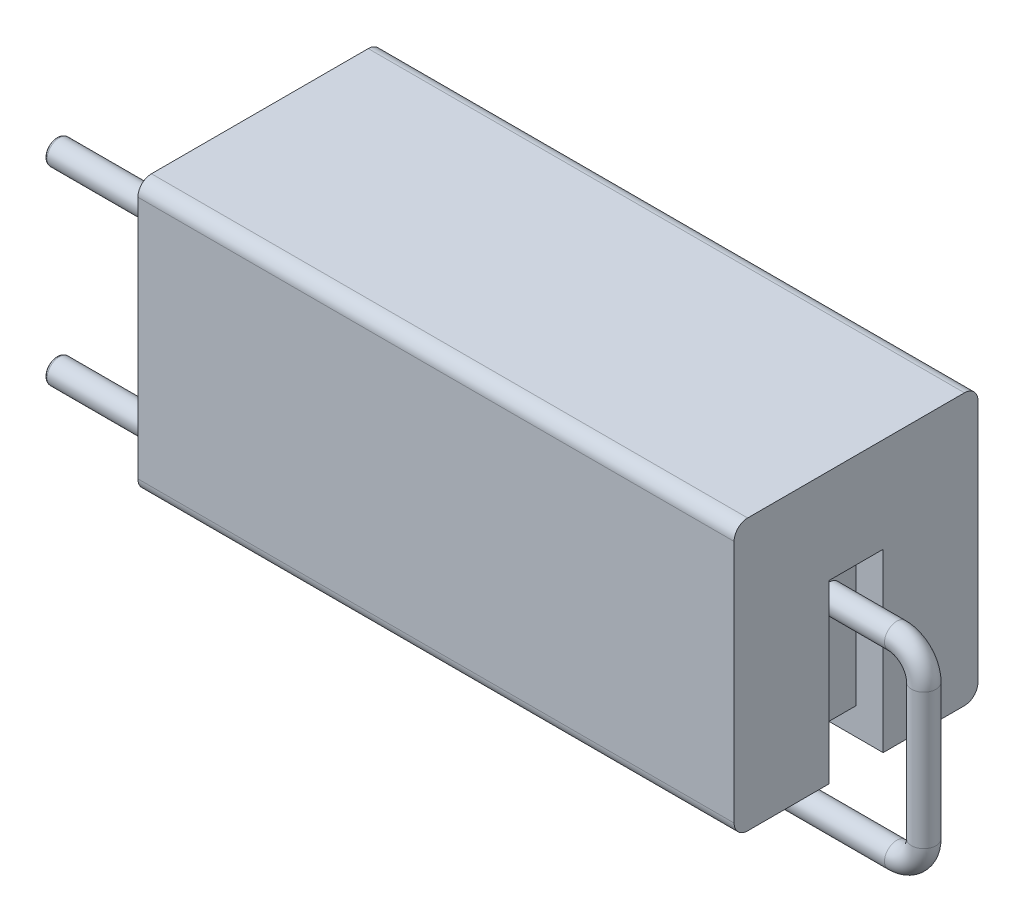
from build123d import *

# Parameters (mm, degrees)
SKETCH1_W           = 22
SKETCH1_H           = 10
BOSS_EXTRUDE1_DEPTH = 9
FILLET2_R           = 0.5
CUT_EXTRUDE4_DEPTH  = 1
SKETCH8_W           = 2
SKETCH8_H           = 6.5
CUT_EXTRUDE5_DEPTH  = 1
CUT_EXTRUDE6_DEPTH  = 1
SKETCH14_R          = 0.45
SKETCH15_R          = 0.45
FILLET4_R           = 0.1


with BuildPart() as part:
    # Sketch1 → Boss-Extrude1 (new body)
    with BuildSketch(Plane.XY):
        with Locations((11, -5)):
            Rectangle(SKETCH1_W, SKETCH1_H)
    extrude(amount=BOSS_EXTRUDE1_DEPTH)

    # Fillet2
    fillet2_edges = [part.edges().sort_by_distance(p)[0] for p in [
        (11, 0, 9),
        (11, 0, 0),
        (11, -10, 0),
        (11, -10, 9),
    ]]
    fillet(fillet2_edges, radius=FILLET2_R)

    # 3DSketch1 → Cut-Extrude4 (cut)
    with BuildSketch(Plane(origin=(22, -10, 5.5), x_dir=(0, 0.9557790087219501, -0.29408584883752314), z_dir=(1, 0, 0))):
        Polygon((0, 0), (6.212563557, 1.911558017), (6.800735254, 0), (0.588171698, -1.911558017), align=None)
    extrude(amount=-CUT_EXTRUDE4_DEPTH, mode=Mode.SUBTRACT)

    # Sketch8 → Cut-Extrude5 (cut)
    with BuildSketch(Plane.ZY):
        with Locations((4.5, -6.75)):
            Rectangle(SKETCH8_W, SKETCH8_H)
    extrude(amount=-CUT_EXTRUDE5_DEPTH, mode=Mode.SUBTRACT)

    # Sketch6 → Cut-Extrude6 (cut)
    with BuildSketch(Plane.XZ.offset(10)):
        Polygon((1, 5.5), (1, 3.5), (3, 3.5), (3, 1), (19, 1), (19, 3.5), (21, 3.5), (21, 5.5), (19, 5.5), (19, 8), (3, 8), (3, 5.5), align=None)
    extrude(amount=-CUT_EXTRUDE6_DEPTH, mode=Mode.SUBTRACT)

    # Sweep2: sweep along a curve in space
    with BuildLine() as sweep2_path:
        Line((21, -5, 4.5), (23.5, -5, 4.5))
        ThreePointArc((24.5, -6, 4.5), (24.207106781, -5.292893219, 4.5), (23.5, -5, 4.5))
        Line((24.5, -6, 4.5), (24.5, -11, 4.5))
        ThreePointArc((23.5, -12, 4.5), (24.207106781, -11.707106781, 4.5), (24.5, -11, 4.5))
        Line((23.5, -12, 4.5), (-7.5, -12, 4.5))
    # Sketch14 → Sweep2 (sweep)
    with BuildSketch(Plane(origin=(21, 0, 0), x_dir=(0, 0, -1), z_dir=(1, 0, 0))):
        with Locations((-4.5, -5)):
            Circle(SKETCH14_R)
    sweep(path=sweep2_path.line)

    # Sweep3: sweep along a curve in space
    with BuildLine() as sweep3_path:
        Line((1, -5, 4.5), (-7.5, -5, 4.5))
    # Sketch15 → Sweep3 (sweep)
    with BuildSketch(Plane.ZY.offset(-1)):
        with Locations((4.5, -5)):
            Circle(SKETCH15_R)
    sweep(path=sweep3_path.line)

    # Fillet4
    fillet4_edges = [part.edges().sort_by_distance(p)[0] for p in [
        (-7.5, -12, 4.95),
        (-7.5, -5, 4.05),
    ]]
    fillet(fillet4_edges, radius=FILLET4_R)


solid = part.part
